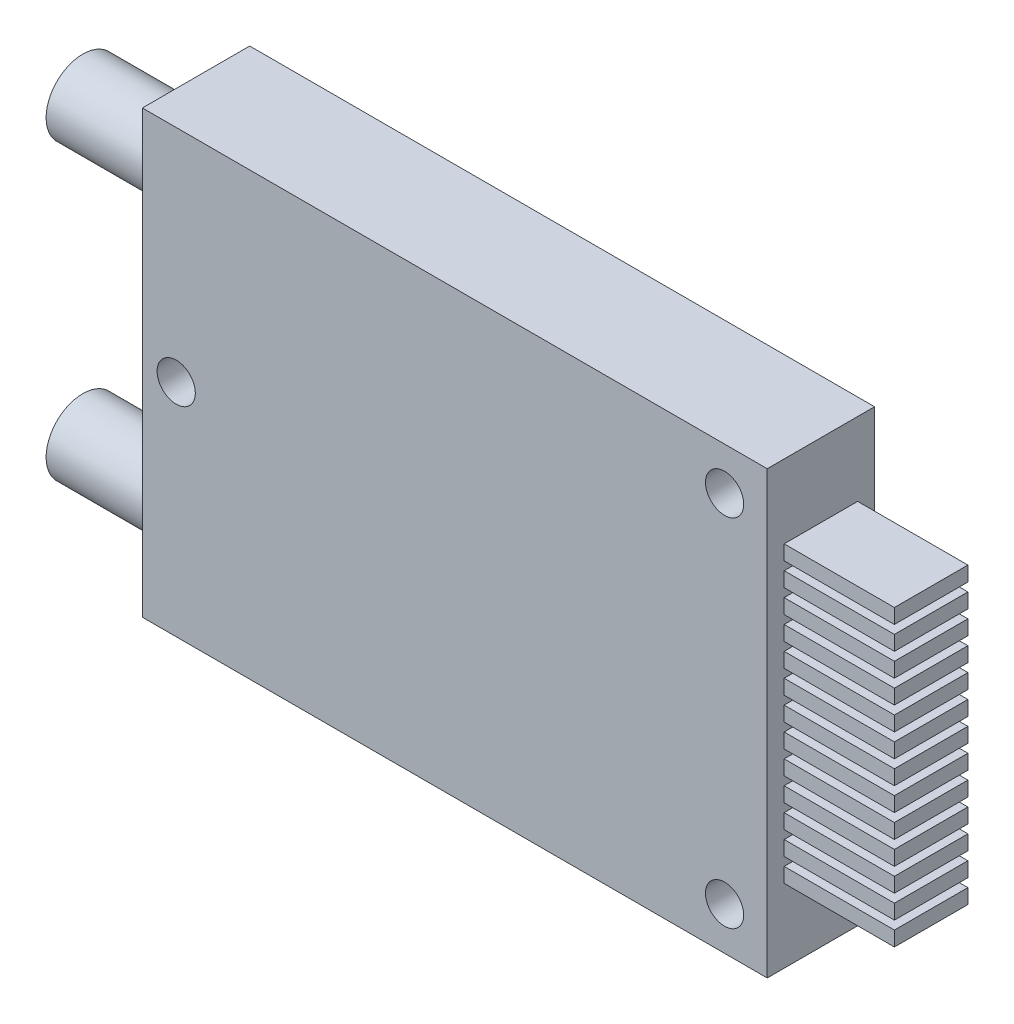
from build123d import *

# Parameters (mm, degrees)
SKETCH1_W           = 42.5
SKETCH1_H           = 30
BOSS_EXTRUDE1_DEPTH = 7.3
CUT_EXTRUDE1_REACH  = 9.3
SKETCH2_R           = 1.3
SKETCH3_R           = 2.5
BOSS_EXTRUDE2_DEPTH = 7.7
SKETCH4_W           = 5
SKETCH4_H           = 1
BOSS_EXTRUDE3_DEPTH = 7.5


with BuildPart() as part:
    # Sketch1 → Boss-Extrude1 (new body)
    with BuildSketch(Plane.XY):
        Rectangle(SKETCH1_W, SKETCH1_H)
    extrude(amount=BOSS_EXTRUDE1_DEPTH)

    # Sketch2 → Cut-Extrude1 (cut, up to next)
    with BuildSketch(Plane.XY.offset(7.3), mode=Mode.PRIVATE) as cut_extrude1_sk1:
        with Locations((18.35, -12.1)):
            Circle(SKETCH2_R)
    cut_extrude1_tool1 = extrude(cut_extrude1_sk1.sketch, amount=-CUT_EXTRUDE1_REACH, mode=Mode.PRIVATE) & part.part
    add(cut_extrude1_tool1.solids().sort_by_distance((18.35, -12.1, 7.3))[0], mode=Mode.SUBTRACT)
    # Sketch2 → Cut-Extrude1 (cut, up to next)
    with BuildSketch(Plane.XY.offset(7.3), mode=Mode.PRIVATE) as cut_extrude1_sk2:
        with Locations((18.35, 12.1)):
            Circle(SKETCH2_R)
    cut_extrude1_tool2 = extrude(cut_extrude1_sk2.sketch, amount=-CUT_EXTRUDE1_REACH, mode=Mode.PRIVATE) & part.part
    add(cut_extrude1_tool2.solids().sort_by_distance((18.35, 12.1, 7.3))[0], mode=Mode.SUBTRACT)
    # Sketch2 → Cut-Extrude1 (cut, up to next)
    with BuildSketch(Plane.XY.offset(7.3), mode=Mode.PRIVATE) as cut_extrude1_sk3:
        with Locations((-18.95, 0)):
            Circle(SKETCH2_R)
    cut_extrude1_tool3 = extrude(cut_extrude1_sk3.sketch, amount=-CUT_EXTRUDE1_REACH, mode=Mode.PRIVATE) & part.part
    add(cut_extrude1_tool3.solids().sort_by_distance((-18.95, 0, 7.3))[0], mode=Mode.SUBTRACT)

    # Sketch3 → Boss-Extrude2 (add)
    with BuildSketch(Plane.ZY.offset(21.25)):
        with Locations((3.65, 10)):
            Circle(SKETCH3_R)
        with Locations((3.65, -10)):
            Circle(SKETCH3_R)
    extrude(amount=BOSS_EXTRUDE2_DEPTH)

    # Sketch4 → Boss-Extrude3 (add)
    with BuildSketch(Plane(origin=(21.25, 0, 0), x_dir=(0, 0, -1), z_dir=(1, 0, 0))):
        with Locations((-3.65, 9.5)):
            Rectangle(SKETCH4_W, SKETCH4_H)
        with Locations((-3.65, 7.916666667)):
            Rectangle(SKETCH4_W, SKETCH4_H)
        with Locations((-3.65, 6.333333333)):
            Rectangle(SKETCH4_W, SKETCH4_H)
        with Locations((-3.65, 4.75)):
            Rectangle(SKETCH4_W, SKETCH4_H)
        with Locations((-3.65, 3.166666667)):
            Rectangle(SKETCH4_W, SKETCH4_H)
        with Locations((-3.65, 1.583333333)):
            Rectangle(SKETCH4_W, SKETCH4_H)
        with Locations((-3.65, 0)):
            Rectangle(SKETCH4_W, SKETCH4_H)
        with Locations((-3.65, -1.583333333)):
            Rectangle(SKETCH4_W, SKETCH4_H)
        with Locations((-3.65, -3.166666667)):
            Rectangle(SKETCH4_W, SKETCH4_H)
        with Locations((-3.65, -4.75)):
            Rectangle(SKETCH4_W, SKETCH4_H)
        with Locations((-3.65, -6.333333333)):
            Rectangle(SKETCH4_W, SKETCH4_H)
        with Locations((-3.65, -7.916666667)):
            Rectangle(SKETCH4_W, SKETCH4_H)
        with Locations((-3.65, -9.5)):
            Rectangle(SKETCH4_W, SKETCH4_H)
    extrude(amount=BOSS_EXTRUDE3_DEPTH)


solid = part.part
